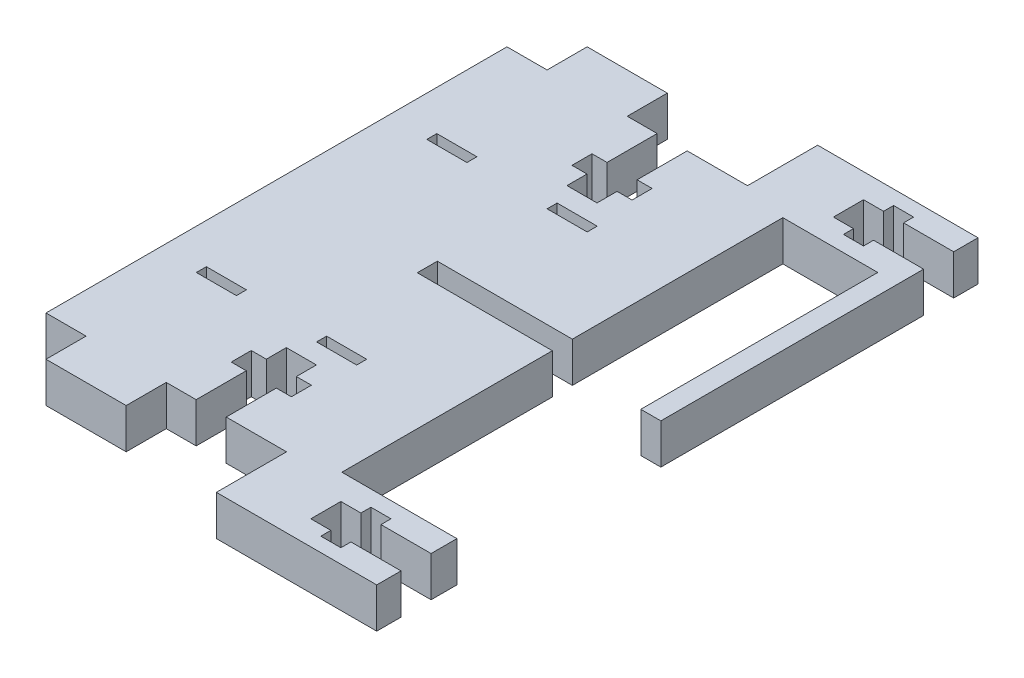
from build123d import *

# Parameters (mm, degrees)
BOSS_EXTRUDE1_DEPTH = 6.35
SKETCH2_W           = 6.35
SKETCH2_H           = 1.5875
CUT_EXTRUDE1_DEPTH  = 6.35
BOSS_EXTRUDE2_START = -6.35
SKETCH4_W           = 24.326613467
SKETCH4_H           = 69.85
BOSS_EXTRUDE2_DEPTH = 6.35
SKETCH5_W           = 25.4
SKETCH5_H           = 3.175
CUT_EXTRUDE3_DEPTH  = 6.35
SKETCH7_W           = 19.923596682
SKETCH7_H           = 95.25
CUT_EXTRUDE4_DEPTH  = 6.35
SKETCH8_W           = 15.043251586
SKETCH8_H           = 69.85
CUT_EXTRUDE5_DEPTH  = 6.35
SKETCH9_W           = 3.175
SKETCH9_H           = 95.25
BOSS_EXTRUDE3_DEPTH = 6.35
SKETCH10_W          = 17.539756693
SKETCH10_H          = 95.25
CUT_EXTRUDE7_DEPTH  = 6.35
SKETCH3_W           = 4.7625
SKETCH3_H           = 14.2875
SKETCH3_W_2         = 9.525
SKETCH3_H_2         = 3.175
CUT_EXTRUDE8_DEPTH  = 6.35
SKETCH11_W          = 14.2875
SKETCH11_H          = 4.7625
SKETCH11_W_2        = 3.175
SKETCH11_H_2        = 7.9375
CUT_EXTRUDE9_DEPTH  = 6.35
SKETCH14_W          = 14.575398065
SKETCH14_H          = 32.31050226
CUT_EXTRUDE11_DEPTH = 6.35


with BuildPart() as part:
    # Sketch1 → Boss-Extrude1 (new body)
    with BuildSketch(Plane(origin=(0, 0, 0), x_dir=(1, 0, 0), z_dir=(0, 1, 0))):
        Polygon((38.1, 65.0875), (84.214756693, 65.0875), (84.214756693, -30.1625), (38.1, -30.1625), (38.1, -19.05), (19.05, -19.05), (19.05, -25.4), (6.35, -25.4), (6.35, -19.05), (0, -19.05), (0, 0), (0, 34.925), (0, 53.975), (6.35, 53.975), (6.35, 60.325), (19.05, 60.325), (19.05, 53.975), (38.1, 53.975), align=None)
        Polygon((38.1, 34.925), (44.45, 38.591174209), (44.45, 52.3875), (74.689756693, 52.3875), (77.864756693, 50.8), (77.864756693, -15.875), (74.689756693, -17.4625), (44.45, -17.4625), (44.45, -3.666174209), (38.1, 0), align=None, mode=Mode.SUBTRACT)
    extrude(amount=BOSS_EXTRUDE1_DEPTH)

    # Sketch2 → Cut-Extrude1 (cut)
    with BuildSketch(Plane(origin=(0, 6.35, 0), x_dir=(1, 0, 0), z_dir=(0, 1, 0))):
        with Locations((9.525, 35.71875)):
            Rectangle(SKETCH2_W, SKETCH2_H)
        with Locations((9.525, -0.79375)):
            Rectangle(SKETCH2_W, SKETCH2_H)
        with Locations((28.575, 35.71875)):
            Rectangle(SKETCH2_W, SKETCH2_H)
        with Locations((28.575, -0.79375)):
            Rectangle(SKETCH2_W, SKETCH2_H)
    extrude(amount=-CUT_EXTRUDE1_DEPTH, mode=Mode.SUBTRACT)

    # Sketch4 → Boss-Extrude2 (add)
    with BuildSketch(Plane(origin=(0, 6.35, 0), x_dir=(1, 0, 0), z_dir=(0, 1, 0)).offset(BOSS_EXTRUDE2_START)):
        with Locations((49.82644996, 17.4625)):
            Rectangle(SKETCH4_W, SKETCH4_H)
    extrude(amount=BOSS_EXTRUDE2_DEPTH)

    # Sketch5 → Cut-Extrude3 (cut)
    with BuildSketch(Plane(origin=(0, 6.35, 0), x_dir=(1, 0, 0), z_dir=(0, 1, 0))):
        with Locations((61.989756693, 17.4625)):
            Rectangle(SKETCH5_W, SKETCH5_H)
        with Locations((36.589756693, 17.4625)):
            Rectangle(SKETCH5_W, SKETCH5_H)
    extrude(amount=-CUT_EXTRUDE3_DEPTH, mode=Mode.SUBTRACT)

    # Sketch7 → Cut-Extrude4 (cut)
    with BuildSketch(Plane(origin=(0, 6.35, 0), x_dir=(1, 0, 0), z_dir=(0, 1, 0))):
        with Locations((91.001555034, 17.4625)):
            Rectangle(SKETCH7_W, SKETCH7_H)
    extrude(amount=-CUT_EXTRUDE4_DEPTH, mode=Mode.SUBTRACT)

    # Sketch8 → Cut-Extrude5 (cut)
    with BuildSketch(Plane.XZ):
        with Locations((52.803374207, -17.4625)):
            Rectangle(SKETCH8_W, SKETCH8_H)
    extrude(amount=-CUT_EXTRUDE5_DEPTH, mode=Mode.SUBTRACT)

    # Sketch9 → Boss-Extrude3 (add)
    with BuildSketch(Plane.XZ):
        with Locations((61.9125, -17.4625)):
            Rectangle(SKETCH9_W, SKETCH9_H)
    extrude(amount=-BOSS_EXTRUDE3_DEPTH)

    # Sketch10 → Cut-Extrude7 (cut)
    with BuildSketch(Plane.XZ):
        with Locations((72.269878347, -17.4625)):
            Rectangle(SKETCH10_W, SKETCH10_H)
    extrude(amount=-CUT_EXTRUDE7_DEPTH, mode=Mode.SUBTRACT)

    # Sketch3 → Cut-Extrude8 (cut)
    with BuildSketch(Plane(origin=(0, 6.35, 0), x_dir=(1, 0, 0), z_dir=(0, 1, 0))):
        with Locations((26.168267374, 46.83125)):
            Rectangle(SKETCH3_W, SKETCH3_H)
        with Locations((26.168267374, 44.45)):
            Rectangle(SKETCH3_W_2, SKETCH3_H_2)
        with Locations((26.168267374, -9.525)):
            Rectangle(SKETCH3_W_2, SKETCH3_H_2)
        with Locations((26.168267374, -11.90625)):
            Rectangle(SKETCH3_W, SKETCH3_H)
    extrude(amount=-CUT_EXTRUDE8_DEPTH, mode=Mode.SUBTRACT)

    # Sketch11 → Cut-Extrude9 (cut)
    with BuildSketch(Plane.XZ):
        with Locations((56.35625, 23.932056084)):
            Rectangle(SKETCH11_W, SKETCH11_H)
        with Locations((53.975, 23.932056084)):
            Rectangle(SKETCH11_W_2, SKETCH11_H_2)
        with Locations((53.975, -58.857056084)):
            Rectangle(SKETCH11_W_2, SKETCH11_H_2)
        with Locations((56.35625, -58.857056084)):
            Rectangle(SKETCH11_W, SKETCH11_H)
    extrude(amount=-CUT_EXTRUDE9_DEPTH, mode=Mode.SUBTRACT)

    # Sketch14 → Cut-Extrude11 (cut)
    with BuildSketch(Plane(origin=(0, 6.35, 0), x_dir=(1, 0, 0), z_dir=(0, 1, 0))):
        with Locations((67.612699033, -1.30724887)):
            Rectangle(SKETCH14_W, SKETCH14_H)
    extrude(amount=-CUT_EXTRUDE11_DEPTH, mode=Mode.SUBTRACT)


solid = part.part
